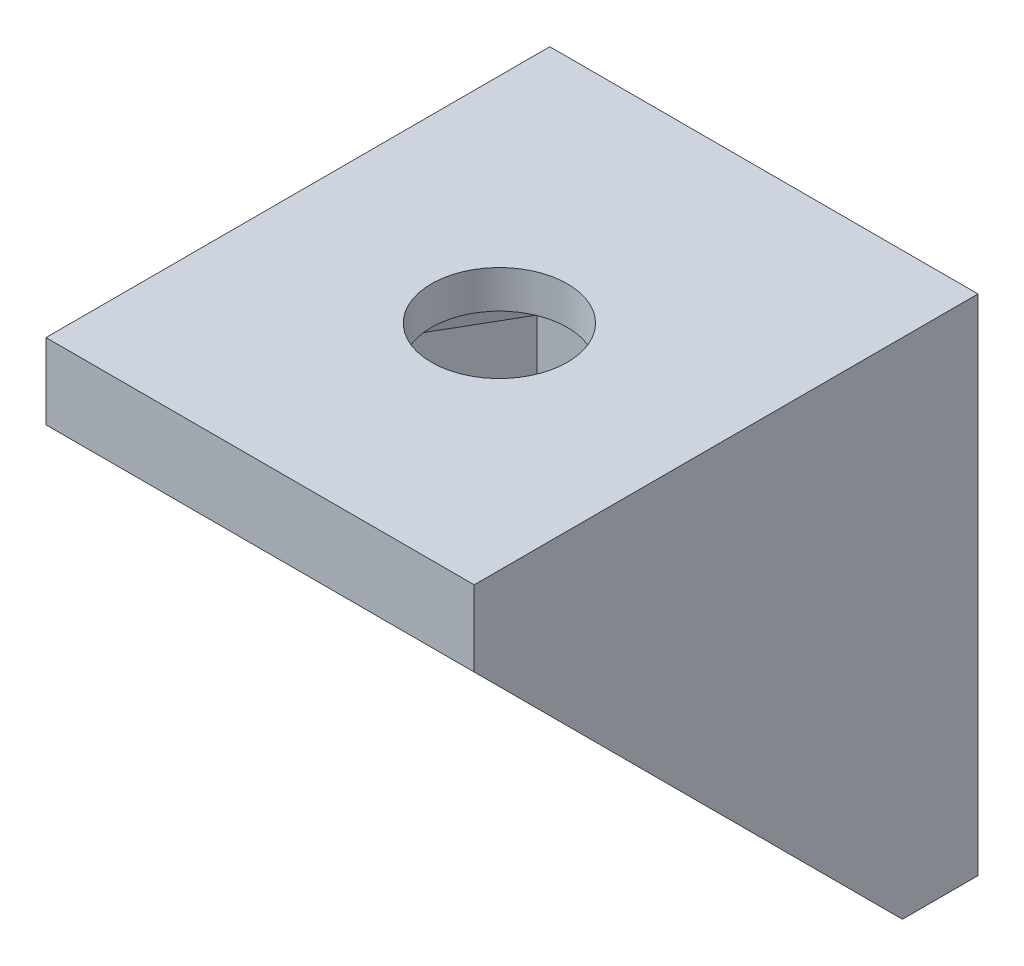
from build123d import *

# Parameters (mm, degrees)
BOSS_EXTRUDE1_DEPTH   = 8.5
SKETCH2_W             = 17
SKETCH2_H             = 17
CUT_EXTRUDE1_DEPTH    = 6
CUT_EXTRUDE2_REACH    = 5
CORTE_EXTRUS_O1_REACH = 22
ESBO_O1_R             = 2.7
CORTE_EXTRUS_O2_DEPTH = 1.5


with BuildPart() as part:
    # Sketch1 → Boss-Extrude1 (new body, symmetric)
    with BuildSketch(Plane(origin=(0, 0, 0), x_dir=(0, 0, -1), z_dir=(1, 0, 0))):
        Polygon((0, 0), (-20, 0), (-20, -3), (-11.5, -11.5), (-3, -20), (0, -20), align=None)
    extrude(amount=BOSS_EXTRUDE1_DEPTH, both=True)

    # Sketch2 → Cut-Extrude1 (cut, symmetric)
    with BuildSketch(Plane(origin=(0, 0, 0), x_dir=(0, 0, -1), z_dir=(1, 0, 0))):
        with Locations((-11.5, -11.5)):
            Rectangle(SKETCH2_W, SKETCH2_H)
    extrude(amount=CUT_EXTRUDE1_DEPTH, both=True, mode=Mode.SUBTRACT)

    # Sketch3 → Cut-Extrude2 (cut, up to next)
    with BuildSketch(Plane.XY.offset(3), mode=Mode.PRIVATE) as cut_extrude2_sk1:
        with BuildLine():
            Line((-3, -9), (-3, -12))
            ThreePointArc((-3, -12), (0, -15), (3, -12))
            Line((3, -12), (3, -9))
            ThreePointArc((3, -9), (0, -6), (-3, -9))
        make_face()
    cut_extrude2_tool1 = extrude(cut_extrude2_sk1.sketch, amount=-CUT_EXTRUDE2_REACH, mode=Mode.PRIVATE) & part.part
    add(cut_extrude2_tool1.solids().sort_by_distance((0, -10.5, 3))[0], mode=Mode.SUBTRACT)

    # Esboço1 → Corte-extrusão1 (cut, up to next)
    with BuildSketch(Plane(origin=(0, 0, 0), x_dir=(1, 0, 0), z_dir=(0, 1, 0)), mode=Mode.PRIVATE) as corte_extrus_o1_sk1:
        with Locations((0, -10.5)):
            Circle(ESBO_O1_R)
    corte_extrus_o1_tool1 = extrude(corte_extrus_o1_sk1.sketch, amount=-CORTE_EXTRUS_O1_REACH, mode=Mode.PRIVATE) & part.part
    add(corte_extrus_o1_tool1.solids().sort_by_distance((0, 0, 10.5))[0], mode=Mode.SUBTRACT)

    # Esboço3 → Corte-extrusão2 (cut)
    with BuildSketch(Plane.XZ.offset(3)):
        Polygon((0, 14.7), (-2.424871131, 14.7), (-3.637306696, 12.6), (-4.849742261, 10.5), (-3.637306696, 8.4), (-2.424871131, 6.3), (0, 6.3), (2.424871131, 6.3), (3.637306696, 8.4), (4.849742261, 10.5), (3.637306696, 12.6), (2.424871131, 14.7), align=None)
    extrude(amount=-CORTE_EXTRUS_O2_DEPTH, mode=Mode.SUBTRACT)


solid = part.part
